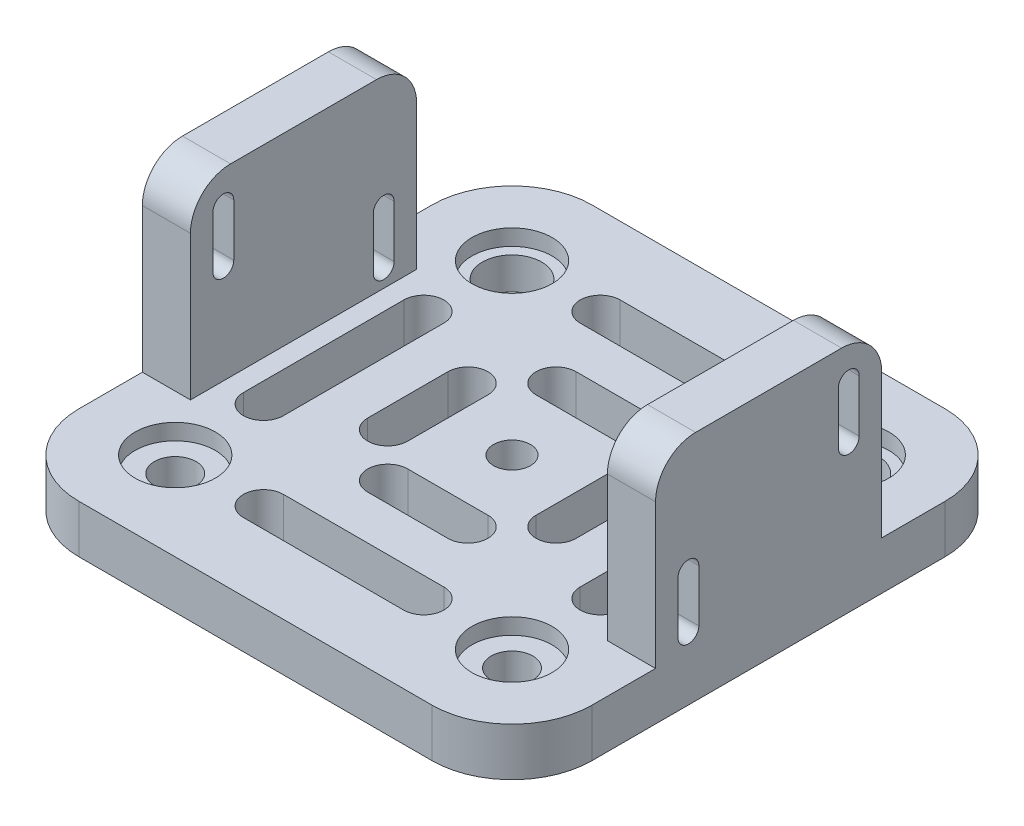
from build123d import *

# Parameters (mm, degrees)
SKETCH1_W                        = 64
SKETCH1_H                        = 64
BOSS_EXTRUDE1_DEPTH              = 6
F_4_6_4_6_DIAMETER_HOLE1_D       = 4.6
CBORE_FOR_M6_5_SHSS1_D           = 7.4
CBORE_FOR_M6_5_SHSS1_CBORE_D     = 10
CBORE_FOR_M6_5_SHSS1_CBORE_DEPTH = 2
M10X1_0_TAPPED_HOLE1_D           = 5.2
M10X1_0_TAPPED_HOLE1_CBORE_D     = 10
M10X1_0_TAPPED_HOLE1_CBORE_DEPTH = 2
BOSS_EXTRUDE4_START              = -32
SKETCH15_W                       = 28.2
SKETCH15_H                       = 29
BOSS_EXTRUDE4_DEPTH              = 6
BOSS_EXTRUDE5_START              = 32
SKETCH16_W                       = 28.2
SKETCH16_H                       = 29
BOSS_EXTRUDE5_DEPTH              = 6
CUT_EXTRUDE3_DEPTH               = 7
FILLET3_R                        = 10
FILLET4_R                        = 5


with BuildPart() as part:
    # Sketch1 → Boss-Extrude1 (new body)
    with BuildSketch(Plane(origin=(0, 6, 0), x_dir=(1, 0, 0), z_dir=(0, 1, 0))):
        Rectangle(SKETCH1_W, SKETCH1_H)
    extrude(amount=-BOSS_EXTRUDE1_DEPTH)

    # Ø4.6 (4.6) Diameter Hole1 (through all)
    with Locations(Plane(origin=(0, 0, 0), x_dir=(-1, 0, 0), z_dir=(0, -1, 0))):
        with Locations((0, 0)):
            Hole(F_4_6_4_6_DIAMETER_HOLE1_D / 2)

    # CBORE for M6.5 SHSS1 (through all)
    with Locations(Plane(origin=(0, 6, 0), x_dir=(1, 0, 0), z_dir=(0, 1, 0))):
        with Locations((21, 21), (-21, 21)):
            CounterBoreHole(CBORE_FOR_M6_5_SHSS1_D / 2, CBORE_FOR_M6_5_SHSS1_CBORE_D / 2, CBORE_FOR_M6_5_SHSS1_CBORE_DEPTH)

    # M10x1.0 Tapped Hole1 (through all)
    with Locations(Plane(origin=(0, 6, 0), x_dir=(1, 0, 0), z_dir=(0, 1, 0))):
        with Locations((-21, -21), (-21, 21), (21, -21)):
            CounterBoreHole(M10X1_0_TAPPED_HOLE1_D / 2, M10X1_0_TAPPED_HOLE1_CBORE_D / 2, M10X1_0_TAPPED_HOLE1_CBORE_DEPTH)

    # Sketch15 → Boss-Extrude4 (add)
    with BuildSketch(Plane(origin=(0, 0, 0), x_dir=(0, 0, -1), z_dir=(1, 0, 0)).offset(BOSS_EXTRUDE4_START)):
        with Locations((0, 14.5)):
            Rectangle(SKETCH15_W, SKETCH15_H)
        with BuildLine():
            Line((-11.3, 18.4), (-11.3, 24.9))
            ThreePointArc((-11.3, 24.9), (-10, 26.2), (-8.7, 24.9))
            Line((-8.7, 24.9), (-8.7, 18.4))
            ThreePointArc((-8.7, 18.4), (-10, 17.1), (-11.3, 18.4))
        make_face(mode=Mode.SUBTRACT)
        with BuildLine():
            Line((8.7, 8.25), (8.7, 14.75))
            ThreePointArc((8.7, 14.75), (10, 16.05), (11.3, 14.75))
            Line((11.3, 14.75), (11.3, 8.25))
            ThreePointArc((11.3, 8.25), (10, 6.95), (8.7, 8.25))
        make_face(mode=Mode.SUBTRACT)
    extrude(amount=BOSS_EXTRUDE4_DEPTH)

    # Sketch16 → Boss-Extrude5 (add)
    with BuildSketch(Plane(origin=(0, 0, 0), x_dir=(0, 0, -1), z_dir=(1, 0, 0)).offset(BOSS_EXTRUDE5_START)):
        with Locations((0, 14.5)):
            Rectangle(SKETCH16_W, SKETCH16_H)
        with BuildLine():
            Line((-11.3, 7.9), (-11.3, 14.4))
            ThreePointArc((-11.3, 14.4), (-10, 15.7), (-8.7, 14.4))
            Line((-8.7, 14.4), (-8.7, 7.9))
            ThreePointArc((-8.7, 7.9), (-10, 6.6), (-11.3, 7.9))
        make_face(mode=Mode.SUBTRACT)
        with BuildLine():
            Line((8.7, 18.4), (8.7, 24.9))
            ThreePointArc((8.7, 24.9), (10, 26.2), (11.3, 24.9))
            Line((11.3, 24.9), (11.3, 18.4))
            ThreePointArc((11.3, 18.4), (10, 17.1), (8.7, 18.4))
        make_face(mode=Mode.SUBTRACT)
    extrude(amount=-BOSS_EXTRUDE5_DEPTH)

    # Sketch17 → Cut-Extrude3 (cut, through all)
    with BuildSketch(Plane(origin=(0, 6, 0), x_dir=(1, 0, 0), z_dir=(0, 1, 0))):
        with BuildLine():
            Line((8, -5), (8, 5))
            ThreePointArc((8, 5), (10.5, 7.5), (13, 5))
            Line((13, 5), (13, -5))
            ThreePointArc((13, -5), (10.5, -7.5), (8, -5))
        make_face()
        with BuildLine():
            Line((18.5, -10), (18.5, 10))
            ThreePointArc((18.5, 10), (21, 12.5), (23.5, 10))
            Line((23.5, 10), (23.5, -10))
            ThreePointArc((23.5, -10), (21, -12.5), (18.5, -10))
        make_face()
        with BuildLine():
            Line((-5, -8), (5, -8))
            ThreePointArc((5, -8), (7.5, -10.5), (5, -13))
            Line((5, -13), (-5, -13))
            ThreePointArc((-5, -13), (-7.5, -10.5), (-5, -8))
        make_face()
        with BuildLine():
            Line((-10, -18.5), (10, -18.5))
            ThreePointArc((10, -18.5), (12.5, -21), (10, -23.5))
            Line((10, -23.5), (-10, -23.5))
            ThreePointArc((-10, -23.5), (-12.5, -21), (-10, -18.5))
        make_face()
        with BuildLine():
            Line((-8, 5), (-8, -5))
            ThreePointArc((-8, -5), (-10.5, -7.5), (-13, -5))
            Line((-13, -5), (-13, 5))
            ThreePointArc((-13, 5), (-10.5, 7.5), (-8, 5))
        make_face()
        with BuildLine():
            Line((-18.5, 10), (-18.5, -10))
            ThreePointArc((-18.5, -10), (-21, -12.5), (-23.5, -10))
            Line((-23.5, -10), (-23.5, 10))
            ThreePointArc((-23.5, 10), (-21, 12.5), (-18.5, 10))
        make_face()
        with BuildLine():
            Line((5, 8), (-5, 8))
            ThreePointArc((-5, 8), (-7.5, 10.5), (-5, 13))
            Line((-5, 13), (5, 13))
            ThreePointArc((5, 13), (7.5, 10.5), (5, 8))
        make_face()
        with BuildLine():
            Line((10, 18.5), (-10, 18.5))
            ThreePointArc((-10, 18.5), (-12.5, 21), (-10, 23.5))
            Line((-10, 23.5), (10, 23.5))
            ThreePointArc((10, 23.5), (12.5, 21), (10, 18.5))
        make_face()
    extrude(amount=-CUT_EXTRUDE3_DEPTH, mode=Mode.SUBTRACT)

    # Fillet3
    fillet3_edges = [part.edges().sort_by_distance(p)[0] for p in [
        (-32, 3, -32),
        (32, 3, -32),
        (32, 3, 32),
        (-32, 3, 32),
    ]]
    fillet(fillet3_edges, radius=FILLET3_R)

    # Fillet4
    fillet4_edges = [part.edges().sort_by_distance(p)[0] for p in [
        (-29, 29, -14.1),
        (-29, 29, 14.1),
        (29, 29, -14.1),
        (29, 29, 14.1),
    ]]
    fillet(fillet4_edges, radius=FILLET4_R)


solid = part.part
